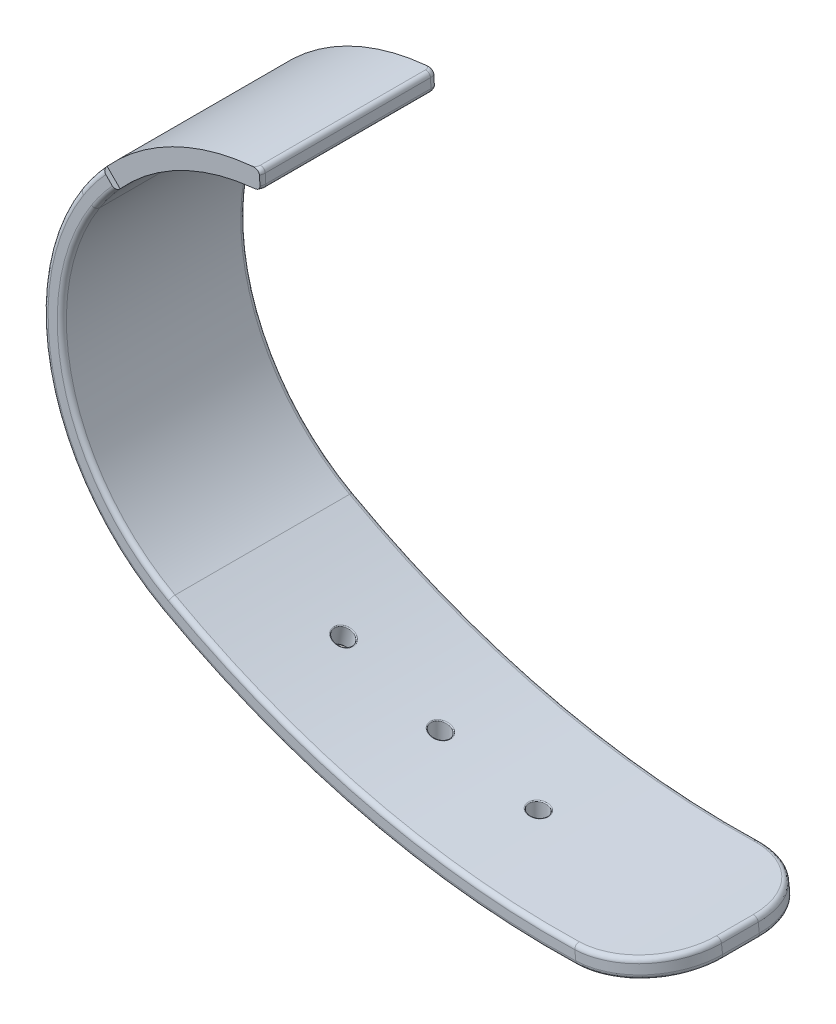
from build123d import *

# Parameters (mm, degrees)
EXTRU_MINCE1_DEPTH      = 10
CONG_10_R               = 8
CONG_8_R                = 1
ESQUISSE4_R             = 1
ENL_V_MAT_EXTRU_4_DEPTH = 56.453206863
ESQUISSE6_R             = 1
ENL_V_MAT_EXTRU_5_DEPTH = 59.647867864
CONG_11_R               = 0.5
ENL_V_MAT_EXTRU_6_DEPTH = 0.5
ENL_V_MAT_EXTRU_7_DEPTH = 0.5
CONG_12_R               = 0.1


with BuildPart() as part:
    # Esquisse1 → Extru.-Mince1 (new body, symmetric)
    with BuildSketch(Plane.XY):
        with BuildLine():
            ThreePointArc((0, 0), (-10.031897648, -3.032022179), (-17.602146756, -10.279329083))
            ThreePointArc((-17.602146756, -10.279329083), (-20.551817965, -28.28401568), (-9.40717851, -42.729302493))
            ThreePointArc((-9.40717851, -42.729302493), (15.781492887, -51.86670264), (42.558784808, -52.835147592))
            Line((42.558784808, -52.835147592), (42.797755112, -54.820819567))
            ThreePointArc((42.797755112, -54.820819567), (15.399704344, -53.829923848), (-10.372898045, -44.480697874))
            ThreePointArc((-10.372898045, -44.480697874), (-22.490937781, -28.773724103), (-19.283635017, -9.196463797))
            ThreePointArc((-19.283635017, -9.196463797), (-11.040474878, -1.304951835), (-0.116852994, 1.996583426))
            Line((-0.116852994, 1.996583426), (0, 0))
        make_face()
    extrude(amount=EXTRU_MINCE1_DEPTH, both=True)

    # Congé10
    cong_10_edges = [part.edges().sort_by_distance(p)[0] for p in [
        (42.67826996, -53.827983579, 10),
        (42.67826996, -53.827983579, -10),
    ]]
    fillet(cong_10_edges, radius=CONG_10_R)

    # Congé8
    cong_8_edges = [part.edges().sort_by_distance(p)[0] for p in [
        (-0.058426497, 0.998291713, 10),
        (-0.058426497, 0.998291713, -10),
    ]]
    fillet(cong_8_edges, radius=CONG_8_R)

    # Esquisse4 → Enlèv. mat.-Extru.4 (cut, through all)
    with BuildSketch(Plane(origin=(0, 0, 0), x_dir=(1, 0, 0), z_dir=(0, 1, 0))):
        with Locations((20.654296422, 0)):
            Circle(ESQUISSE4_R)
        with Locations((9.969615092, 0)):
            Circle(ESQUISSE4_R)
    extrude(amount=-ENL_V_MAT_EXTRU_4_DEPTH, mode=Mode.SUBTRACT)

    # Esquisse6 → Enlèv. mat.-Extru.5 (cut, through all)
    with BuildSketch(Plane(origin=(0, 0, 0), x_dir=(0.984807753, -0.173648178, 0), z_dir=(0.173648178, 0.984807753, 0))):
        with Locations((7.587754721, 0)):
            Circle(ESQUISSE6_R)
    extrude(amount=-ENL_V_MAT_EXTRU_5_DEPTH, mode=Mode.SUBTRACT)

    # Congé11
    cong_11_edges = [part.edges().sort_by_distance(p)[0] for p in [
        (11.868563475, -51.011032119, 10),
        (-20.551817965, -28.28401568, 10),
        (42.558784808, -52.835147592, 0),
        (42.797755112, -54.820819567, 0),
        (40.464138995, -55.070240289, -7.660406396),
        (40.464138999, -55.070240289, 7.6604064),
        (-22.490937781, -28.773724103, 10),
        (40.224915464, -53.083865459, -7.660573613),
        (40.224915469, -53.083865459, 7.660573617),
        (-0.116852994, 1.996583426, 0),
        (0, 0, 0),
        (-10.460968601, -3.28902918, -10),
        (-10.460968601, -3.28902918, 10),
        (-0.292387737, -0.019023521, -9.707213318),
        (-0.292387737, -0.019023521, 9.707213318),
        (-11.469758202, -1.561556777, 10),
        (-11.469758202, -1.561556777, -10),
        (-0.40923316, 1.977716568, -9.707196612),
        (-0.409233178, 1.977716566, 9.70719659),
        (11.486561158, -52.976369072, 10),
        (-22.490937781, -28.773724103, -10),
        (-20.551817965, -28.28401568, -10),
        (11.868563475, -51.011032119, -10),
        (11.486561158, -52.976369072, -10),
    ]]
    fillet(cong_11_edges, radius=CONG_11_R)

    # Esquisse7 → Enlèv. mat.-Extru.6 (cut)
    with BuildSketch(Plane.XY.offset(10)):
        Polygon((-14.476099296, -8.320207469), (-18.547221395, -4.24908537), (-4.308564503, 9.989571522), (7.614544734, -1.933537715), align=None)
    extrude(amount=-ENL_V_MAT_EXTRU_6_DEPTH, mode=Mode.SUBTRACT)

    # Esquisse8 → Enlèv. mat.-Extru.7 (cut)
    with BuildSketch(Plane(origin=(0, 0, -10), x_dir=(-1, 0, 0), z_dir=(0, 0, -1))):
        Polygon((14.476099296, -8.320207469), (18.547221395, -4.24908537), (4.308564503, 9.989571522), (-7.614544734, -1.933537715), align=None)
    extrude(amount=-ENL_V_MAT_EXTRU_7_DEPTH, mode=Mode.SUBTRACT)

    # Congé12
    cong_12_edges = [part.edges().sort_by_distance(p)[0] for p in [
        (8.969615092, -52.327860111, 0),
        (8.969615092, -50.252650062, 0),
        (19.654296422, -54.549872666, 0),
        (19.654296422, -52.528707102, 0),
        (-1.878133543, -48.588792051, 0),
        (-1.521853143, -46.568225496, 0),
    ]]
    fillet(cong_12_edges, radius=CONG_12_R)


solid = part.part
